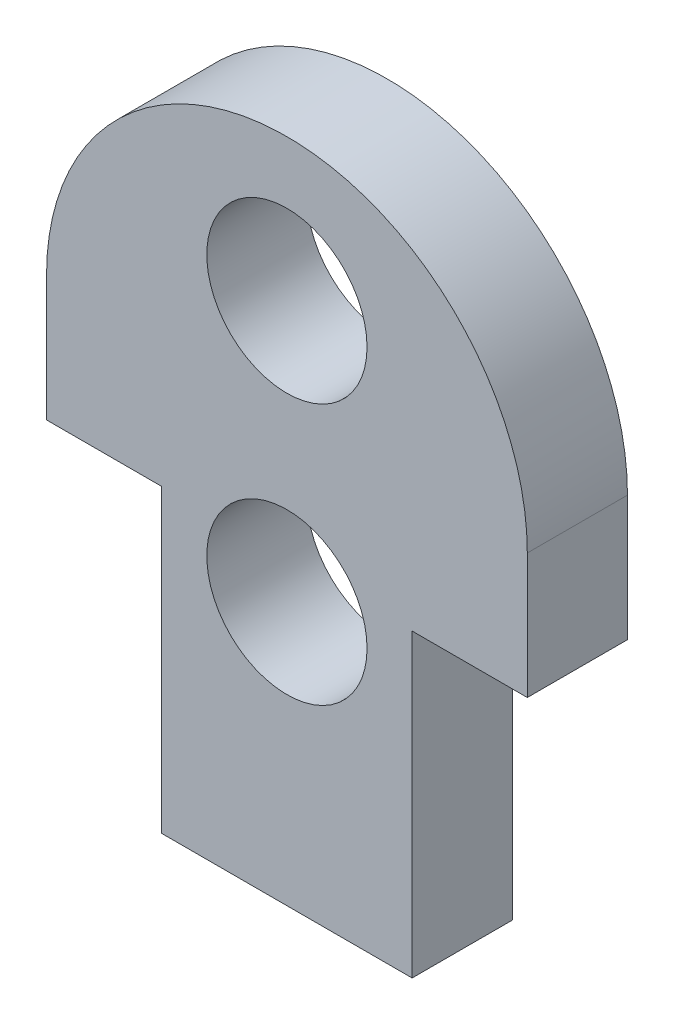
from build123d import *

# Parameters (mm, degrees)
BOSS_EXTRUDE1_DEPTH = 4
SKETCH2_W           = 2.5
SKETCH2_H           = 4
CUT_EXTRUDE1_DEPTH  = 4
SKETCH3_R           = 3.2
CUT_EXTRUDE2_DEPTH  = 5


with BuildPart() as part:
    # Sketch1 → Boss-Extrude1 (new body)
    with BuildSketch(Plane.XY):
        with BuildLine():
            Line((0, 0), (10, 0))
            Line((10, 0), (10, 4))
            Line((10, 4), (12.5, 4))
            Line((12.5, 4), (12.5, 8))
            Line((12.5, 8), (10, 8))
            Line((10, 8), (10, 12))
            Line((10, 12), (14.6, 12))
            Line((14.6, 12), (14.6, 17))
            ThreePointArc((14.6, 17), (5, 26.6), (-4.6, 17))
            Line((-4.6, 17), (-4.6, 12))
            Line((-4.6, 12), (0, 12))
            Line((0, 12), (0, 8))
            Line((0, 8), (-2.5, 8))
            Line((-2.5, 8), (-2.5, 4))
            Line((-2.5, 4), (0, 4))
            Line((0, 4), (0, 0))
        make_face()
    extrude(amount=BOSS_EXTRUDE1_DEPTH)

    # Sketch2 → Cut-Extrude1 (cut)
    with BuildSketch(Plane.XY.offset(4)):
        with Locations((-1.25, 6)):
            Rectangle(SKETCH2_W, SKETCH2_H)
        with Locations((11.25, 6)):
            Rectangle(SKETCH2_W, SKETCH2_H)
    extrude(amount=-CUT_EXTRUDE1_DEPTH, mode=Mode.SUBTRACT)

    # Sketch3 → Cut-Extrude2 (cut, through all)
    with BuildSketch(Plane.XY):
        with Locations((5, 20.921172359)):
            Circle(SKETCH3_R)
        with Locations((5, 10.5)):
            Circle(SKETCH3_R)
    extrude(amount=CUT_EXTRUDE2_DEPTH, mode=Mode.SUBTRACT)


solid = part.part
